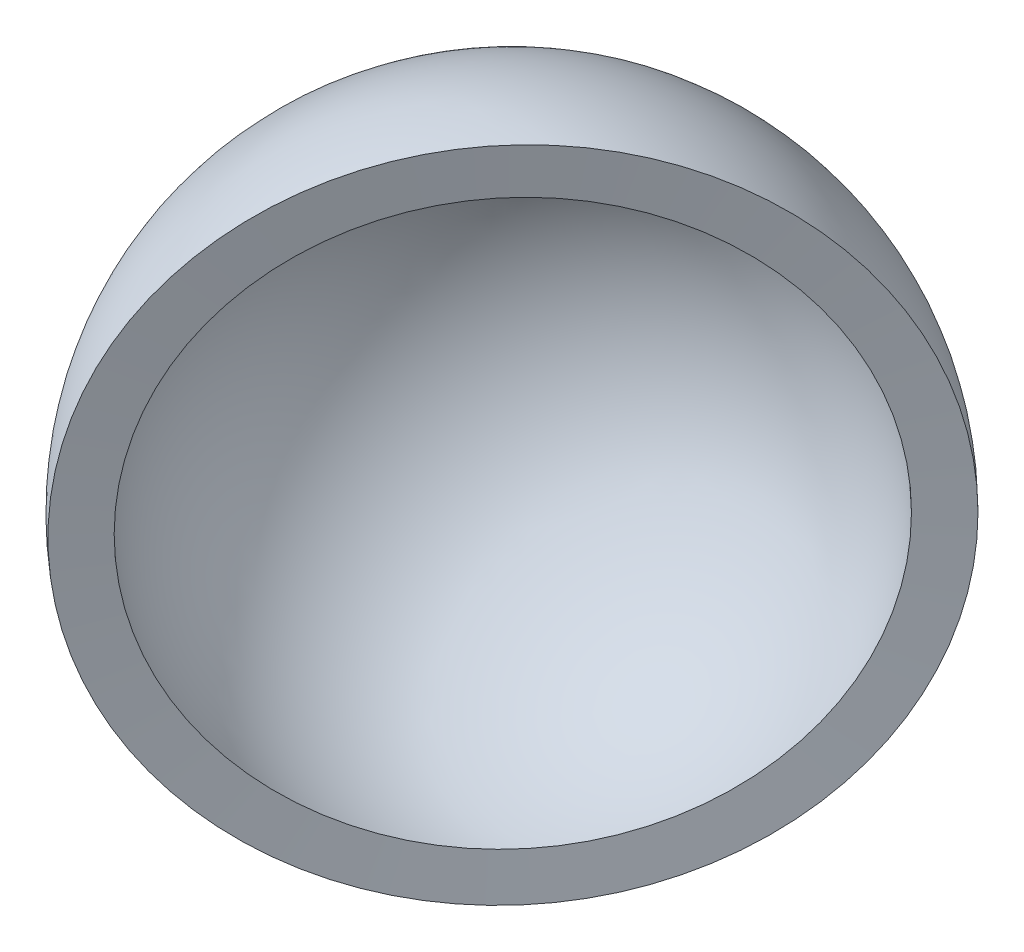
from build123d import *


with BuildPart() as part:
    # Croquis1 → Revolución1 (revolve)
    with BuildSketch(Plane(origin=(0, 0, 0), x_dir=(1, 0, 0), z_dir=(0, 1, 0))):
        with BuildLine():
            Line((-7.396653837, 6.729748287), (-8.628454316, 7.850485765))
            Line((-8.628454316, 7.850485765), (-8.631017383, 7.852920157))
            Line((-8.631017383, 7.852920157), (-8.286681368, 8.21545665))
            Line((-8.286681368, 8.21545665), (-8.284118301, 8.213022257))
            ThreePointArc((-8.284118301, 8.213022257), (-0.025136306, 11.665321204), (8.248646878, 8.248646878))
            Line((8.248646878, 8.248646878), (7.071067812, 7.071067812))
            ThreePointArc((7.071067812, 7.071067812), (-0.235852326, 9.997218297), (-7.396653837, 6.729748287))
        make_face()
    revolve(axis=Axis((-7.396653837, 0, -6.729748287), (-0.739665384, 0, -0.672974829)))


solid = part.part
